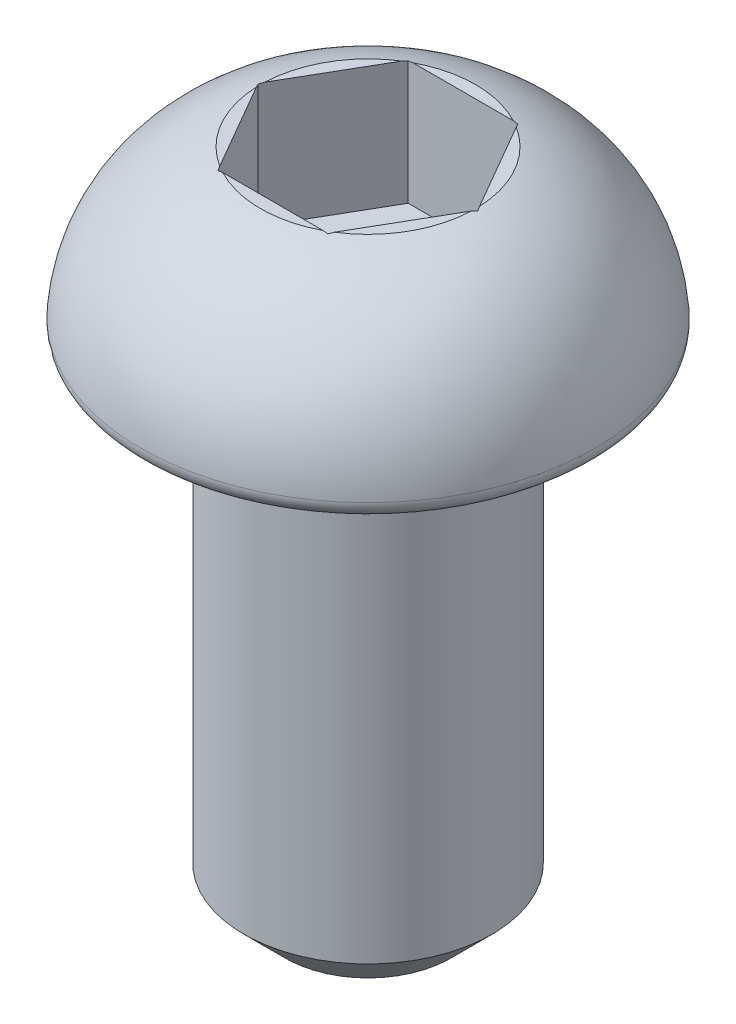
from build123d import *

# Parameters (mm, degrees)
FILLET_1_R          = 0.2
CUT_EXTRUDE_1_DEPTH = 1.5
SKETCH_3_R          = 1.5
EXTRUDE_1_DEPTH     = 6
CHAMFER_1_SIZE      = 0.5


with BuildPart() as part:
    # 草图1 → 旋转1 (revolve)
    with BuildSketch(Plane.XY):
        with BuildLine():
            Line((0, 0), (0, 2))
            Line((0, 2), (1.3, 2))
            ThreePointArc((1.3, 2), (2.370691821, 1.250626571), (2.75, 0))
            Line((2.75, 0), (0, 0))
        make_face()
    revolve(axis=Axis((0, 0, 0), (0, 1, 0)))

    # 圆角1
    fillet_1_edges = [part.edges().sort_by_distance(p)[0] for p in [
        (-2.75, 0, 0),
    ]]
    fillet(fillet_1_edges, radius=FILLET_1_R)

    # 草图2 → 切除-拉伸1 (cut)
    with BuildSketch(Plane(origin=(0, 2, 0), x_dir=(1, 0, 0), z_dir=(0, 1, 0))):
        Polygon((1.327905619, 0), (0.66395281, 1.15), (-0.66395281, 1.15), (-1.327905619, 0), (-0.66395281, -1.15), (0.66395281, -1.15), align=None)
    extrude(amount=-CUT_EXTRUDE_1_DEPTH, mode=Mode.SUBTRACT)

    # 草图3 → 凸台-拉伸1 (add)
    with BuildSketch(Plane.XZ):
        Circle(SKETCH_3_R)
    extrude(amount=EXTRUDE_1_DEPTH)

    # 倒角1
    chamfer_1_edges = [part.edges().sort_by_distance(p)[0] for p in [
        (-1.5, -6, 0),
    ]]
    chamfer(chamfer_1_edges, length=CHAMFER_1_SIZE)


solid = part.part
